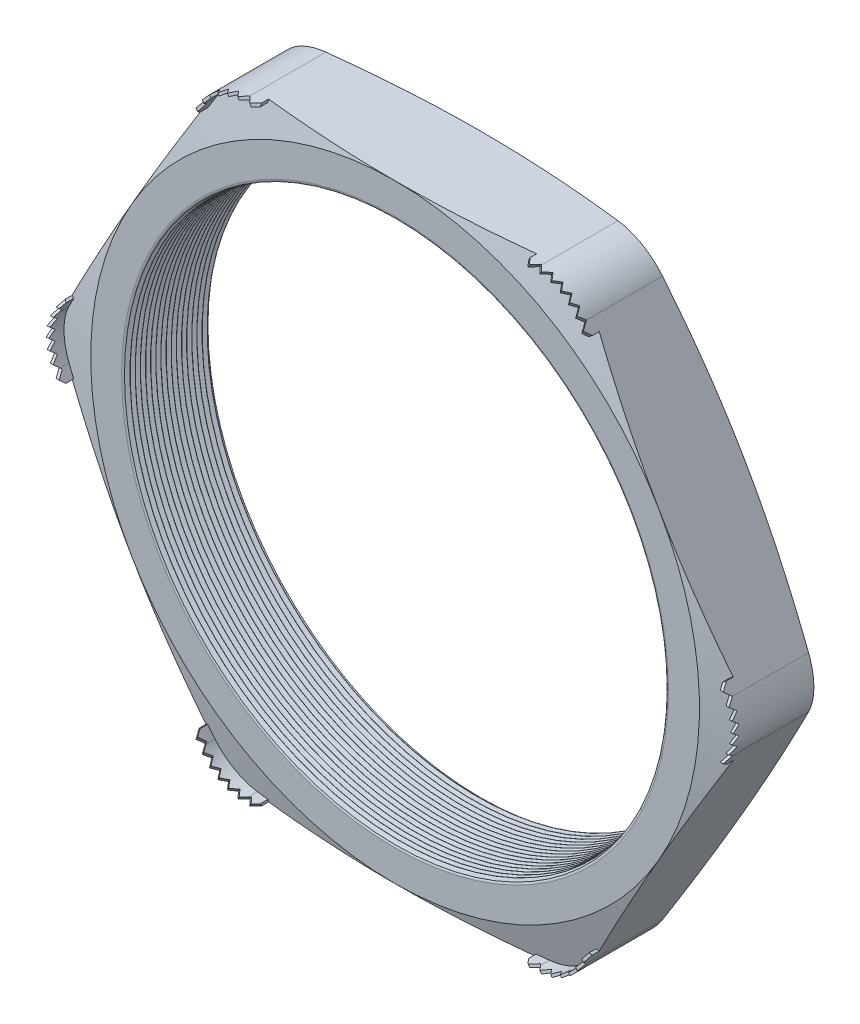
from build123d import *

# Parameters (mm, degrees)
SKETCH1_R          = 16.002
EXTRUDE1_DEPTH     = 5.08
FILLET1_R          = 3.048
FILLET3_R          = 0.2032
LPATTERN1_COUNT    = 17
LPATTERN1_PITCH    = 0.3048
SKETCH4_OUTSIDE_W  = 99.01
SKETCH4_OUTSIDE_H  = 94.374
SKETCH4_OUTSIDE_R  = 18.034
CUT_EXTRUDE1_DEPTH = 6.08
CUT_EXTRUDE1_DRAFT = -75
SKETCH5_OUTSIDE_W  = 99.01
SKETCH5_OUTSIDE_H  = 94.374
SKETCH5_OUTSIDE_R  = 18.034
CUT_EXTRUDE2_DEPTH = 6.0800001
CUT_EXTRUDE2_DRAFT = -75
EXTRUDE2_START     = -0.621198
EXTRUDE2_DEPTH     = 1.484798
CUT_EXTRUDE4_DEPTH = 7.337667975
CIRPATTERN1_COUNT  = 6
CIRPATTERN2_COUNT  = 6


with BuildPart() as part:
    # Sketch1 → Extrude1 (new body)
    with BuildSketch(Plane.XY):
        Polygon((-20.823869509, 0), (-10.411934755, -18.034), (10.411934755, -18.034), (20.823869509, 0), (10.411934755, 18.034), (-10.411934755, 18.034), align=None)
        Circle(SKETCH1_R, mode=Mode.SUBTRACT)
    extrude(amount=EXTRUDE1_DEPTH)

    # Fillet1
    fillet1_edges = [part.edges().sort_by_distance(p)[0] for p in [
        (20.823869509, 0, 2.54),
        (10.411934755, -18.034, 2.54),
        (-10.411934755, -18.034, 2.54),
        (-20.823869509, 0, 2.54),
        (-10.411934755, 18.034, 2.54),
        (10.411934755, 18.034, 2.54),
    ]]
    fillet(fillet1_edges, radius=FILLET1_R)

    # Fillet3
    fillet3_edges = [part.edges().sort_by_distance(p)[0] for p in [
        (-16.002, 0, 0),
        (-16.002, 0, 5.08),
    ]]
    fillet(fillet3_edges, radius=FILLET3_R)

    # Sketch3 → Cut-Revolve1 (revolve, cut)
    with BuildSketch(Plane(origin=(0, 0, 0), x_dir=(1, 0, 0), z_dir=(0, 1, 0)), mode=Mode.PRIVATE) as cut_revolve1_sk:
        Polygon((-16.002, -5.08), (-16.002, -4.786706063), (-16.256, -4.933353032), align=None)
    cut_revolve1 = revolve(cut_revolve1_sk.sketch.rotate(Axis((0, 0, 5.08), (0, 0, -1)), 180), axis=Axis((0, 0, 5.08), (0, 0, -1)), mode=Mode.SUBTRACT)  # turned: the seam where the file's is

    # LPattern1: Cut-Revolve1 ×17
    with Locations(*[(0, 0, -i * LPATTERN1_PITCH) for i in range(1, LPATTERN1_COUNT)]):
        add(cut_revolve1, mode=Mode.SUBTRACT)


with BuildPart() as cut_extrude1_tool:
    # Sketch4 outside → Cut-Extrude1 (with draft: the straight prism first)
    with BuildSketch(Plane(origin=(0, 0, 0), x_dir=(-1, 0, 0), z_dir=(0, 0, -1))):
        Rectangle(SKETCH4_OUTSIDE_W, SKETCH4_OUTSIDE_H)
        Circle(SKETCH4_OUTSIDE_R, mode=Mode.SUBTRACT)
    extrude(amount=-CUT_EXTRUDE1_DEPTH)
    # Cut-Extrude1: the draft: its side faces are tilted about the plane it starts from
    cut_extrude1_sides = [cut_extrude1_tool.faces().sort_by_distance(p)[0] for p in [
        (0, -47.187, 3.04),
        (-49.505, 0, 3.04),
        (0, 47.187, 3.04),
        (49.505, 0, 3.04),
        (18.034, 0, 3.04),
    ]]
    draft(cut_extrude1_sides, Plane(origin=(0, 0, 0), x_dir=(-1, 0, 0), z_dir=(0, 0, -1)), CUT_EXTRUDE1_DRAFT)


with BuildPart() as part_1:
    add(part.part)

    # Cut-Extrude1: cut by cut_extrude1_tool
    add(cut_extrude1_tool.part, mode=Mode.SUBTRACT)


with BuildPart() as cut_extrude2_tool:
    # Sketch5 outside → Cut-Extrude2 (with draft: the straight prism first)
    with BuildSketch(Plane.XY.offset(5.08)):
        Rectangle(SKETCH5_OUTSIDE_W, SKETCH5_OUTSIDE_H)
        Circle(SKETCH5_OUTSIDE_R, mode=Mode.SUBTRACT)
    extrude(amount=-CUT_EXTRUDE2_DEPTH)
    # Cut-Extrude2: the draft: its side faces are tilted about the plane it starts from
    cut_extrude2_sides = [cut_extrude2_tool.faces().sort_by_distance(p)[0] for p in [
        (0, -47.187, 2.03999995),
        (49.505, 0, 2.03999995),
        (0, 47.187, 2.03999995),
        (-49.505, 0, 2.03999995),
        (-18.034, 0, 2.03999995),
    ]]
    draft(cut_extrude2_sides, Plane.XY.offset(5.08), CUT_EXTRUDE2_DRAFT)


with BuildPart() as part_2:
    add(part_1.part)

    # Cut-Extrude2: cut by cut_extrude2_tool
    add(cut_extrude2_tool.part, mode=Mode.SUBTRACT)

    # Sketch2 → Extrude2 (add)
    with BuildSketch(Plane.XY.offset(5.08).offset(EXTRUDE2_START)):
        with BuildLine():
            Line((-8.652171134, 18.034), (-7.940971134, 18.034))
            Line((-7.940971134, 18.034), (-7.940971134, 17.8816))
            Line((-7.940971134, 17.8816), (-8.652171134, 17.8816))
            ThreePointArc((-8.652171134, 17.8816), (-10.099971134, 17.493663159), (-11.159834293, 16.4338))
            Line((-11.159834293, 16.4338), (-11.515434293, 15.817882733))
            Line((-11.515434293, 15.817882733), (-11.647416565, 15.894082733))
            Line((-11.647416565, 15.894082733), (-11.291816565, 16.51))
            ThreePointArc((-11.291816565, 16.51), (-10.176171134, 17.625645431), (-8.652171134, 18.034))
        make_face()
    extrude2 = extrude(amount=EXTRUDE2_DEPTH)

    # Sketch7 → Cut-Extrude4 (cut, through all)
    with BuildSketch(Plane(origin=(-9.728202714, 16.849741366, 0), x_dir=(0.866025404, 0.5, 0), z_dir=(0.5, -0.866025404, 0))):
        Polygon((-2.139917267, 5.03682), (-1.835117267, 5.399532), (-1.530317267, 5.03682), (-1.2192, 5.399532), (-0.9144, 5.03682), (-0.6096, 5.399532), (-0.3048, 5.03682), (0, 5.399532), (0.3048, 5.03682), (0.6096, 5.399532), (0.9144, 5.03682), (1.2192, 5.399532), (1.524, 5.03682), (1.835117267, 5.399532), (2.139917267, 5.03682), (2.139917267, 5.9436), (-2.139917267, 5.9436), align=None)
    cut_extrude4 = extrude(amount=-CUT_EXTRUDE4_DEPTH, mode=Mode.SUBTRACT)

    # CirPattern1: Extrude2 ×6 about axis
    cirpattern1_axis = Axis((0, 0, 0), (0, 0, 1))
    for i in range(1, CIRPATTERN1_COUNT):
        add(extrude2.rotate(cirpattern1_axis, i * 360 / CIRPATTERN1_COUNT))

    # CirPattern2: Cut-Extrude4 ×6 about axis
    cirpattern2_axis = Axis((0, 0, 0), (0, 0, 1))
    for i in range(1, CIRPATTERN2_COUNT):
        add(cut_extrude4.rotate(cirpattern2_axis, i * 360 / CIRPATTERN2_COUNT), mode=Mode.SUBTRACT)


solid = part_2.part
